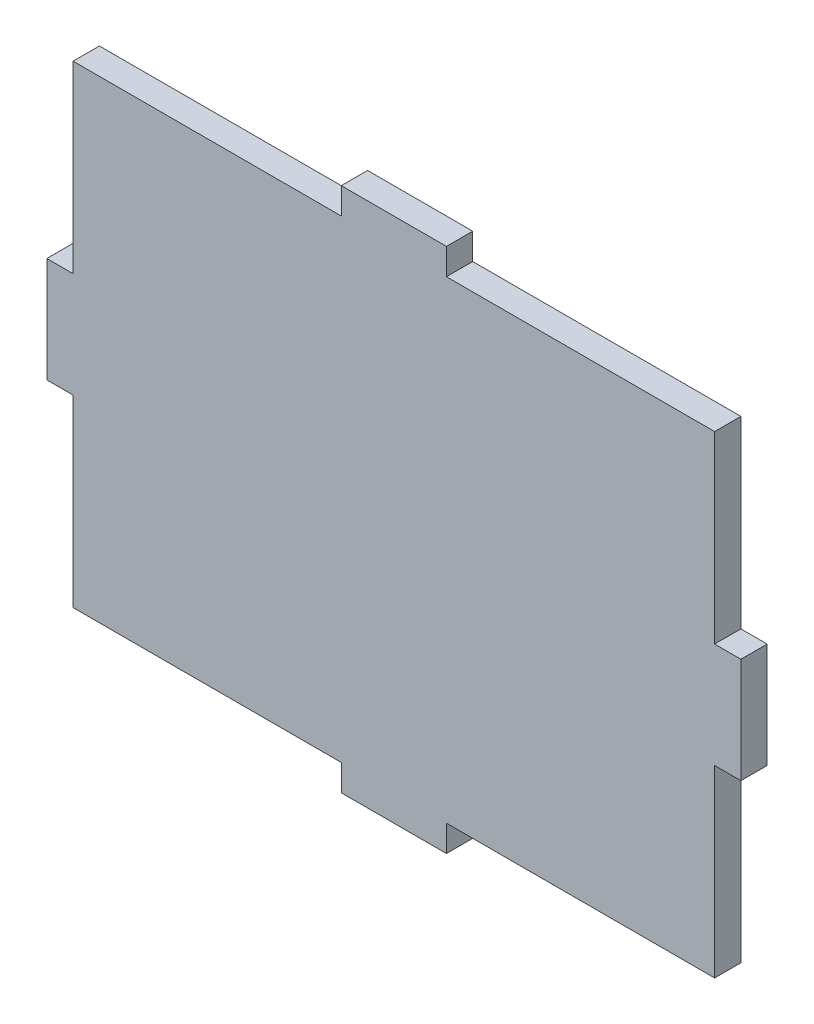
from build123d import *

# Parameters (mm, degrees)
BOSS_EXTRUDE1_DEPTH = 3.175


with BuildPart() as part:
    # Sketch1 → Boss-Extrude1 (new body)
    with BuildSketch(Plane.XY):
        Polygon((-38.735, 6.35), (-41.91, 6.35), (-41.91, -6.35), (-38.735, -6.35), (-38.735, -28.575), (-6.35, -28.575), (-6.35, -31.75), (6.35, -31.75), (6.35, -28.575), (38.735, -28.575), (38.735, -6.35), (41.91, -6.35), (41.91, 6.35), (38.735, 6.35), (38.735, 28.575), (6.35, 28.575), (6.35, 31.75), (-6.35, 31.75), (-6.35, 28.575), (-38.735, 28.575), align=None)
    extrude(amount=BOSS_EXTRUDE1_DEPTH)


solid = part.part
